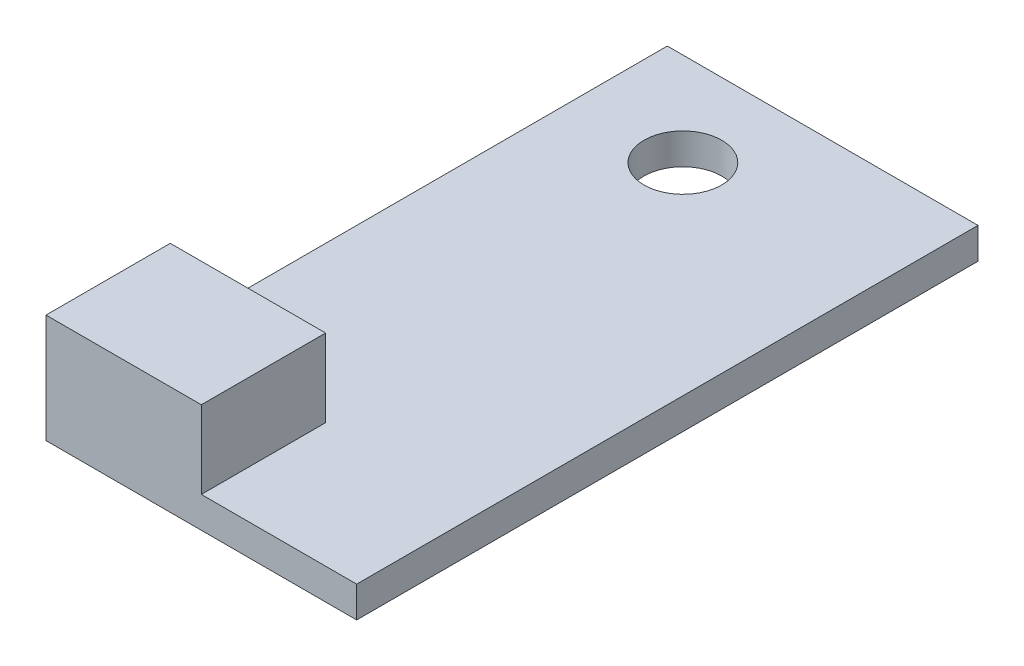
from build123d import *

# Parameters (mm, degrees)
SKETCH1_W           = 100
SKETCH1_H           = 200
BOSS_EXTRUDE1_DEPTH = 10
SKETCH2_W           = 50
SKETCH2_H           = 40
BOSS_EXTRUDE2_DEPTH = 25
SKETCH4_R           = 12.5
CUT_EXTRUDE1_DEPTH  = 25


with BuildPart() as part:
    # Sketch1 → Boss-Extrude1 (new body)
    with BuildSketch(Plane(origin=(0, 0, 0), x_dir=(1, 0, 0), z_dir=(0, 1, 0))):
        with Locations((50, 100)):
            Rectangle(SKETCH1_W, SKETCH1_H)
    extrude(amount=BOSS_EXTRUDE1_DEPTH)

    # Sketch2 → Boss-Extrude2 (add)
    with BuildSketch(Plane(origin=(0, 10, 0), x_dir=(1, 0, 0), z_dir=(0, 1, 0))):
        with Locations((25, 20)):
            Rectangle(SKETCH2_W, SKETCH2_H)
    extrude(amount=BOSS_EXTRUDE2_DEPTH)

    # Sketch4 → Cut-Extrude1 (cut)
    with BuildSketch(Plane(origin=(0, 10, 0), x_dir=(1, 0, 0), z_dir=(0, 1, 0))):
        with Locations((35, 170)):
            Circle(SKETCH4_R)
    extrude(amount=-CUT_EXTRUDE1_DEPTH, mode=Mode.SUBTRACT)


solid = part.part
